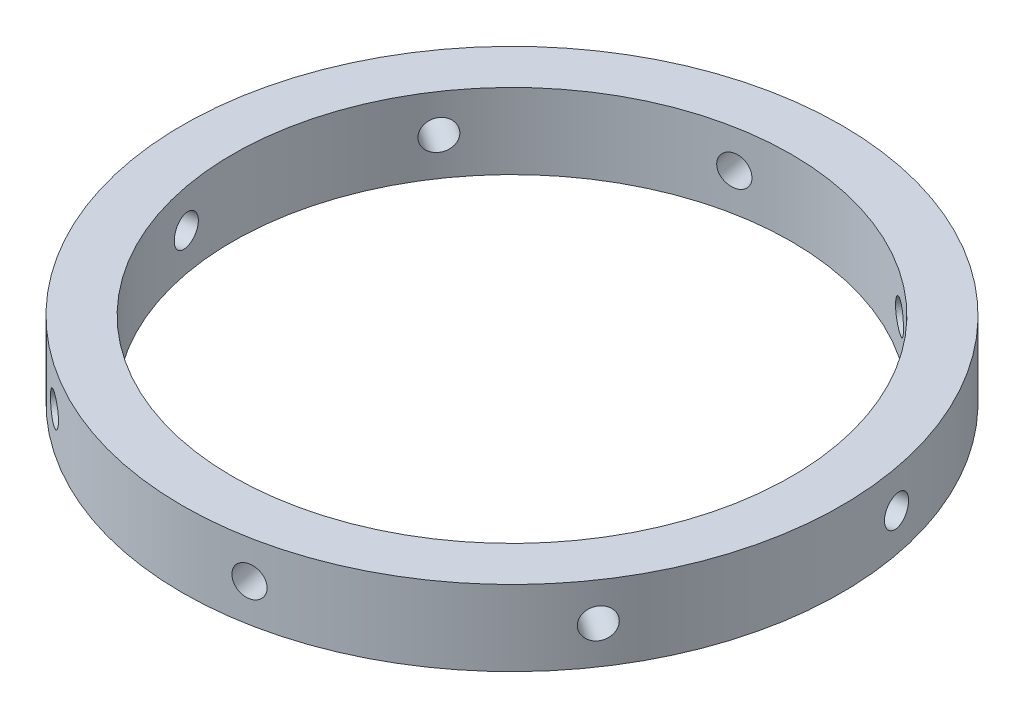
from build123d import *

# Parameters (mm, degrees)
SKETCH1_R           = 65.5
SKETCH1_R_2         = 55.5
BOSS_EXTRUDE1_DEPTH = 15
CIRPATTERN1_COUNT   = 8


with BuildPart() as part:
    # Sketch1 → Boss-Extrude1 (new body)
    with BuildSketch(Plane(origin=(0, 0, 0), x_dir=(1, 0, 0), z_dir=(0, 1, 0))):
        Circle(SKETCH1_R)
        Circle(SKETCH1_R_2, mode=Mode.SUBTRACT)
    extrude(amount=-BOSS_EXTRUDE1_DEPTH)

    # Sketch3 → Ø6.0 (6) Diameter Hole2 (revolve, cut)
    with BuildSketch(Plane(origin=(12.141952512, -7.5, 64.364765122), x_dir=(0.98266817, 0, -0.185373321), z_dir=(0, 1, 0))):
        Polygon((0, 0), (0, 67.301581857), (3, 65.499), (3, 0), align=None)
    f_6_0_6_diameter_hole2 = revolve(axis=Axis((13.319073099, -7.5, 70.604708), (-0.185373321, 0, -0.98266817)), mode=Mode.SUBTRACT)

    # CirPattern1: Ø6.0 (6) Diameter Hole2 ×8 about axis
    cirpattern1_axis = Axis((0, 0, 0), (0, 1, 0))
    for i in range(1, CIRPATTERN1_COUNT):
        add(f_6_0_6_diameter_hole2.rotate(cirpattern1_axis, i * 360 / CIRPATTERN1_COUNT), mode=Mode.SUBTRACT)


solid = part.part
